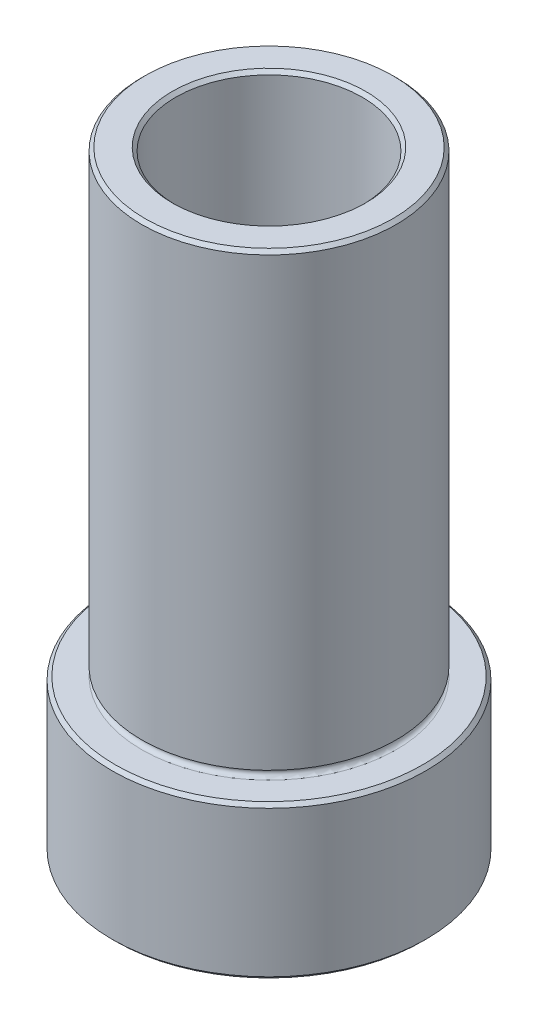
from build123d import *

# Parameters (mm, degrees)
SKIZZE1_R                       = 9.25
AUFSATZ_LINEAR_AUSTRAGEN1_DEPTH = 9
SKIZZE2_R                       = 7.5
AUFSATZ_LINEAR_AUSTRAGEN2_DEPTH = 27
SKIZZE3_R                       = 5.5
SCHNITT_LINEAR_AUSTRAGEN1_DEPTH = 40
FASE1_SIZE                      = 0.2
SKIZZE4_R                       = 0.25


with BuildPart() as part:
    # Skizze1 → Aufsatz-Linear austragen1 (new body)
    with BuildSketch(Plane(origin=(0, 0, 0), x_dir=(1, 0, 0), z_dir=(0, 1, 0))):
        Circle(SKIZZE1_R)
    extrude(amount=AUFSATZ_LINEAR_AUSTRAGEN1_DEPTH)

    # Skizze2 → Aufsatz-Linear austragen2 (add)
    with BuildSketch(Plane(origin=(0, 9, 0), x_dir=(1, 0, 0), z_dir=(0, 1, 0))):
        Circle(SKIZZE2_R)
    extrude(amount=AUFSATZ_LINEAR_AUSTRAGEN2_DEPTH)

    # Skizze3 → Schnitt-Linear austragen1 (cut)
    with BuildSketch(Plane.XZ):
        Circle(SKIZZE3_R)
    extrude(amount=-SCHNITT_LINEAR_AUSTRAGEN1_DEPTH, mode=Mode.SUBTRACT)

    # Fase1
    fase1_edges = [part.edges().sort_by_distance(p)[0] for p in [
        (-5.5, 36, 0),
        (-5.5, 0, 0),
        (-9.25, 0, 0),
        (-9.25, 9, 0),
        (-7.5, 36, 0),
    ]]
    chamfer(fase1_edges, length=FASE1_SIZE)

    # Skizze4 → Schnitt-Rotation1 (revolve, cut)
    with BuildSketch(Plane(origin=(0, 0, 0), x_dir=(0, 0, -1), z_dir=(1, 0, 0))):
        with Locations((-7.5, 9.25)):
            Circle(SKIZZE4_R)
    revolve(axis=Axis((0, 12.492787288, 0), (0, -1, 0)), mode=Mode.SUBTRACT)


solid = part.part
